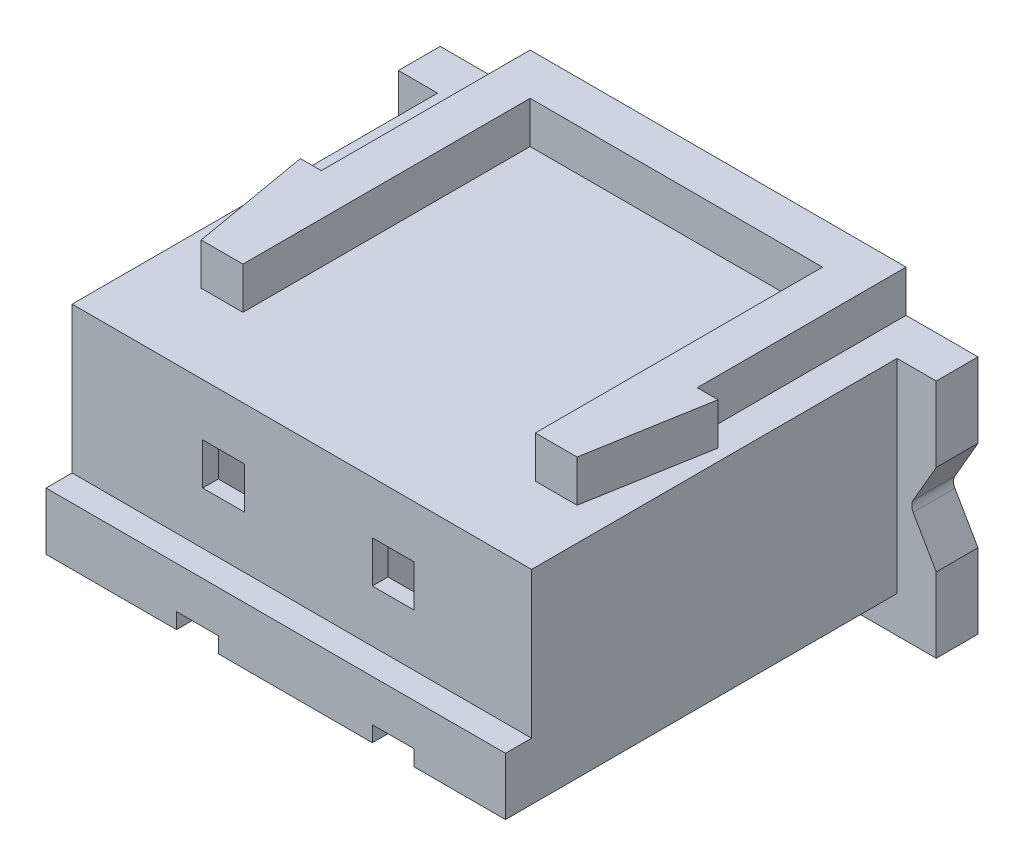
from build123d import *

# Parameters (mm, degrees)
SKETCH1_W           = 8.8
SKETCH1_H           = 4.3
BOSS_EXTRUDE1_DEPTH = 7
SKETCH2_W           = 10.3
SKETCH2_H           = 4.6
BOSS_EXTRUDE2_DEPTH = 0.8
CUT_EXTRUDE1_DEPTH  = 1
FILLET1_R           = 0.2
SKETCH4_W           = 8.8
SKETCH4_H           = 1.5
BOSS_EXTRUDE3_DEPTH = 0.5
SKETCH5_W           = 0.8
SKETCH5_H           = 0.7
CUT_EXTRUDE2_DEPTH  = 3.2
SKETCH6_W           = 0.8
SKETCH6_H           = 0.8
CUT_EXTRUDE3_DEPTH  = 10
BOSS_EXTRUDE4_DEPTH = 0.8
CUT_EXTRUDE4_DEPTH  = 7.5
CUT_EXTRUDE5_DEPTH  = 0.4
BOSS_EXTRUDE5_DEPTH = 0.1


with BuildPart() as part:
    # Sketch1 → Boss-Extrude1 (new body)
    with BuildSketch(Plane.XY):
        Rectangle(SKETCH1_W, SKETCH1_H)
    extrude(amount=BOSS_EXTRUDE1_DEPTH)

    # Sketch2 → Boss-Extrude2 (add)
    with BuildSketch(Plane(origin=(0, 0, 0), x_dir=(-1, 0, 0), z_dir=(0, 0, -1))):
        with Locations((0, -0.15)):
            Rectangle(SKETCH2_W, SKETCH2_H)
    extrude(amount=BOSS_EXTRUDE2_DEPTH)

    # Sketch3 → Cut-Extrude1 (cut)
    with BuildSketch(Plane.XY):
        Polygon((4.65, -0.15), (5.15, -1.016025404), (5.15, 0.716025404), align=None)
    extrude(amount=-CUT_EXTRUDE1_DEPTH, mode=Mode.SUBTRACT)

    # Fillet1
    fillet1_edges = [part.edges().sort_by_distance(p)[0] for p in [
        (4.65, -0.15, -0.4),
    ]]
    fillet(fillet1_edges, radius=FILLET1_R)

    # Sketch4 → Boss-Extrude3 (add)
    with BuildSketch(Plane.XY.offset(7)):
        with Locations((0, -1.4)):
            Rectangle(SKETCH4_W, SKETCH4_H)
    extrude(amount=BOSS_EXTRUDE3_DEPTH)

    # Sketch5 → Cut-Extrude2 (cut)
    with BuildSketch(Plane.XY.offset(7.5)):
        with Locations((-1.5, -1.8)):
            Rectangle(SKETCH5_W, SKETCH5_H)
        with Locations((2.25, -1.8)):
            Rectangle(SKETCH5_W, SKETCH5_H)
    extrude(amount=-CUT_EXTRUDE2_DEPTH, mode=Mode.SUBTRACT)

    # Sketch6 → Cut-Extrude3 (cut)
    with BuildSketch(Plane.XY.offset(7)):
        with Locations((-1.5, 0.75)):
            Rectangle(SKETCH6_W, SKETCH6_H)
        with Locations((1.75, 0.75)):
            Rectangle(SKETCH6_W, SKETCH6_H)
    extrude(amount=-CUT_EXTRUDE3_DEPTH, mode=Mode.SUBTRACT)

    # Sketch7 → Boss-Extrude4 (add)
    with BuildSketch(Plane(origin=(0, 2.15, 0), x_dir=(1, 0, 0), z_dir=(0, 1, 0))):
        Polygon((-3.427970594, -5.5), (-3.827970594, -3.2), (-3.427970594, -3.2), (-3.427970594, 0.8), (3.772029406, 0.8), (3.772029406, -3.2), (4.172029406, -3.2), (3.772029406, -5.5), (2.972029406, -5.5), (2.972029406, 0), (-2.627970594, 0), (-2.627970594, -5.5), align=None)
    extrude(amount=BOSS_EXTRUDE4_DEPTH)

    # Sketch8 → Cut-Extrude4 (cut)
    with BuildSketch(Plane(origin=(0, 0, -0.8), x_dir=(-1, 0, 0), z_dir=(0, 0, -1))):
        Polygon((2.6, 1.746369259), (0.4, 1.746369259), (0.4, -1.053630741), (1.1, -1.053630741), (1.1, -1.453630741), (1.9, -1.453630741), (1.9, -1.053630741), (2.6, -1.053630741), align=None)
        Polygon((-1.15, 1.746369259), (-3.35, 1.746369259), (-3.35, -1.053630741), (-2.65, -1.053630741), (-2.65, -1.453630741), (-1.85, -1.453630741), (-1.85, -1.053630741), (-1.15, -1.053630741), align=None)
    extrude(amount=-CUT_EXTRUDE4_DEPTH, mode=Mode.SUBTRACT)

    # Sketch9 → Cut-Extrude5 (cut)
    with BuildSketch(Plane.XZ.offset(2.15)):
        Polygon((2.65, 7.5), (2.65, 4.3), (1.85, 4.3), (1.85, 7.5), (-1.1, 7.5), (-1.1, 4.3), (-1.9, 4.3), (-1.9, 7.5), (-4.4, 7.5), (-4.4, 0), (4.4, 0), (4.4, 7.5), align=None)
    extrude(amount=-CUT_EXTRUDE5_DEPTH, mode=Mode.SUBTRACT)

    # Sketch10 → Boss-Extrude5 (add)
    with BuildSketch(Plane(origin=(0, 0, -0.8), x_dir=(-1, 0, 0), z_dir=(0, 0, -1))):
        Polygon((-2.213189244, -1.663325944), (-2.120741327, -1.663325944), (-2.120741327, -2.163325944), (-2.165613122, -2.163325944), (-2.165613122, -1.714607995), (-2.242536199, -1.714607995), align=None)
        with BuildLine():
            Line((1.398489442, -1.817172097), (1.353617647, -1.817172097))
            add(Edge.make_bspline(
                [(1.353617647, -1.817172097), (1.353910097, -1.811219114), (1.354484462, -1.799527611), (1.357174218, -1.782481339), (1.361022915, -1.766187796), (1.366464551, -1.750777809), (1.373222591, -1.736115122), (1.38132688, -1.722257977), (1.390926002, -1.709259236), (1.401812678, -1.697239401), (1.413636769, -1.686212605), (1.426394761, -1.676690427), (1.439801193, -1.668645046), (1.453815393, -1.661919154), (1.468595473, -1.656870605), (1.48400731, -1.653124656), (1.500118616, -1.650870893), (1.511095762, -1.650628637), (1.516678544, -1.650505431)],
                knots=[0, 0, 0, 0, 1.7869e-05, 3.5094e-05, 5.1686e-05, 6.8032e-05, 8.4031e-05, 0.000100058, 0.000116104, 0.000132416, 0.000148647, 0.000164532, 0.000180078, 0.00019549, 0.000211074, 0.000226841, 0.000243017, 0.000259759, 0.000259759, 0.000259759, 0.000259759], degree=3))
            add(Edge.make_bspline(
                [(1.516678544, -1.650505431), (1.522161126, -1.650633782), (1.532934204, -1.650885987), (1.548657349, -1.653051848), (1.563625534, -1.656444075), (1.577809501, -1.661203421), (1.591096081, -1.667601196), (1.603585088, -1.675286559), (1.615425204, -1.684175106), (1.626083316, -1.694639936), (1.635870184, -1.705811706), (1.644313363, -1.717738549), (1.651543815, -1.730057018), (1.657570627, -1.742861047), (1.662007218, -1.756271194), (1.665375533, -1.770092223), (1.66727945, -1.784467196), (1.667571653, -1.794196704), (1.667720211, -1.799143251)],
                knots=[0, 0, 0, 0, 1.6441e-05, 3.2306e-05, 4.7516e-05, 6.2435e-05, 7.7085e-05, 9.1652e-05, 0.000106376, 0.000121393, 0.000136374, 0.000150882, 0.000165157, 0.000179183, 0.000193247, 0.000207458, 0.000221808, 0.000236648, 0.000236648, 0.000236648, 0.000236648], degree=3))
            add(Edge.make_bspline(
                [(1.667720211, -1.799143251), (1.667478316, -1.806107228), (1.666998772, -1.819912973), (1.662896718, -1.84020081), (1.656490074, -1.859857013), (1.648776166, -1.875676627), (1.640994388, -1.888424269), (1.633981887, -1.898919799), (1.625772628, -1.91022058), (1.616247128, -1.922288771), (1.605602432, -1.9352189), (1.593742123, -1.949003157), (1.580581626, -1.963499124), (1.571344697, -1.973399924), (1.566558352, -1.978530271)],
                knots=[0, 0, 0, 0, 2.0874e-05, 4.1382e-05, 6.1843e-05, 8.2763e-05, 9.3997e-05, 0.000106637, 0.000120621, 0.000135888, 0.000152753, 0.000170863, 0.000190435, 0.000211484, 0.000211484, 0.000211484, 0.000211484], degree=3))
            Line((1.566558352, -1.978530271), (1.441458192, -2.112043892))
            Line((1.441458192, -2.112043892), (1.674130467, -2.112043892))
            Line((1.674130467, -2.112043892), (1.674130467, -2.163325944))
            Line((1.674130467, -2.163325944), (1.334386878, -2.163325944))
            Line((1.334386878, -2.163325944), (1.528297134, -1.956394854))
            add(Edge.make_bspline(
                [(1.528297134, -1.956394854), (1.533018261, -1.951466524), (1.542086579, -1.942000212), (1.554912661, -1.928179789), (1.566432517, -1.915358426), (1.576720716, -1.903560348), (1.585554074, -1.892612981), (1.593392964, -1.88287088), (1.599673763, -1.873905959), (1.606490248, -1.863514443), (1.613092245, -1.850826969), (1.618765439, -1.835322156), (1.622224703, -1.81936112), (1.622639679, -1.808575115), (1.622848416, -1.803149662)],
                knots=[0, 0, 0, 0, 2.0474e-05, 3.9327e-05, 5.6561e-05, 7.2184e-05, 8.6278e-05, 9.8762e-05, 0.000109683, 0.000119101, 0.000136035, 0.000152448, 0.000168517, 0.00018478, 0.00018478, 0.00018478, 0.00018478], degree=3))
            add(Edge.make_bspline(
                [(1.622848416, -1.803149662), (1.622757596, -1.799738033), (1.622578606, -1.793014369), (1.620998935, -1.783156403), (1.61861172, -1.773647144), (1.615190969, -1.764457341), (1.61067572, -1.755679391), (1.605179523, -1.747302608), (1.598838086, -1.739204185), (1.59150219, -1.731610856), (1.583443402, -1.724656398), (1.574929937, -1.718495815), (1.56592278, -1.71334737), (1.556459905, -1.709126871), (1.546567695, -1.705816102), (1.536227017, -1.703522019), (1.525466443, -1.702081664), (1.518118801, -1.701886783), (1.514374859, -1.701787482)],
                knots=[0, 0, 0, 0, 1.0229e-05, 2.0159e-05, 2.9876e-05, 3.9606e-05, 4.9505e-05, 5.9423e-05, 6.9622e-05, 8.0319e-05, 9.1042e-05, 0.000101521, 0.000111795, 0.000122107, 0.000132559, 0.000143032, 0.000153841, 0.00016507, 0.00016507, 0.00016507, 0.00016507], degree=3))
            add(Edge.make_bspline(
                [(1.514374859, -1.701787482), (1.51046474, -1.70188963), (1.502785912, -1.70209023), (1.491511764, -1.703493468), (1.480756653, -1.705914302), (1.470493524, -1.709225256), (1.460705012, -1.71343362), (1.45143872, -1.718675298), (1.44271545, -1.724930083), (1.434518804, -1.732021591), (1.426966807, -1.739916962), (1.420331539, -1.748718385), (1.414533822, -1.758265159), (1.40947536, -1.768531523), (1.405367405, -1.779610635), (1.402228383, -1.791463164), (1.399744548, -1.804037647), (1.398914759, -1.812721231), (1.398489442, -1.817172097)],
                knots=[0, 0, 0, 0, 1.1729e-05, 2.3035e-05, 3.4018e-05, 4.4756e-05, 5.5343e-05, 6.5928e-05, 7.6628e-05, 8.7492e-05, 9.8403e-05, 0.00010934, 0.000120489, 0.000131867, 0.000143625, 0.00015587, 0.000168619, 0.000182025, 0.000182025, 0.000182025, 0.000182025], degree=3))
        make_face()
    extrude(amount=BOSS_EXTRUDE5_DEPTH)


solid = part.part
